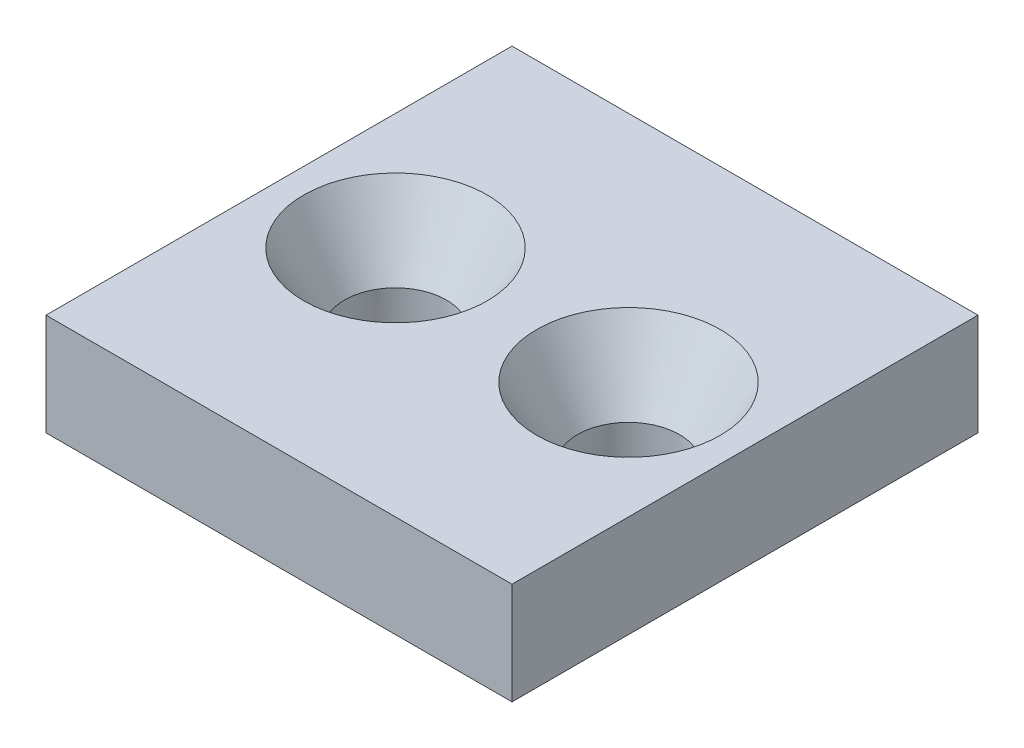
from build123d import *

# Parameters (mm, degrees)
SKETCH1_W                                      = 32
SKETCH1_H                                      = 32
BOSS_EXTRUDE1_DEPTH                            = 7
CSK_FOR_M6_FLAT_HEAD_MACHINE_SCREW1_AT_2_COUNT = 2
CSK_FOR_M6_FLAT_HEAD_MACHINE_SCREW1_AT_2_PITCH = 16


with BuildPart() as part:
    # Sketch1 → Boss-Extrude1 (new body)
    with BuildSketch(Plane(origin=(0, 0, 0), x_dir=(1, 0, 0), z_dir=(0, 1, 0))):
        Rectangle(SKETCH1_W, SKETCH1_H)
    extrude(amount=BOSS_EXTRUDE1_DEPTH)

    # Sketch3 → CSK for M6 Flat Head Machine Screw1 (revolve, cut)
    with BuildSketch(Plane(origin=(-8, 7, 0), x_dir=(0, 0, 1), z_dir=(1, 0, 0))):
        Polygon((0, 0), (0, 7), (3.5, 7), (3.5, 4.849742261), (6.3, 0), align=None)
    csk_for_m6_flat_head_machine_screw1 = revolve(axis=Axis((-8, 13.35, 0), (0, -1, 0)), mode=Mode.SUBTRACT)

    # CSK for M6 Flat Head Machine Screw1 at 2: CSK for M6 Flat Head Machine Screw1 ×2
    with Locations(*[(i * CSK_FOR_M6_FLAT_HEAD_MACHINE_SCREW1_AT_2_PITCH, 0, 0) for i in range(1, CSK_FOR_M6_FLAT_HEAD_MACHINE_SCREW1_AT_2_COUNT)]):
        add(csk_for_m6_flat_head_machine_screw1, mode=Mode.SUBTRACT)


solid = part.part
